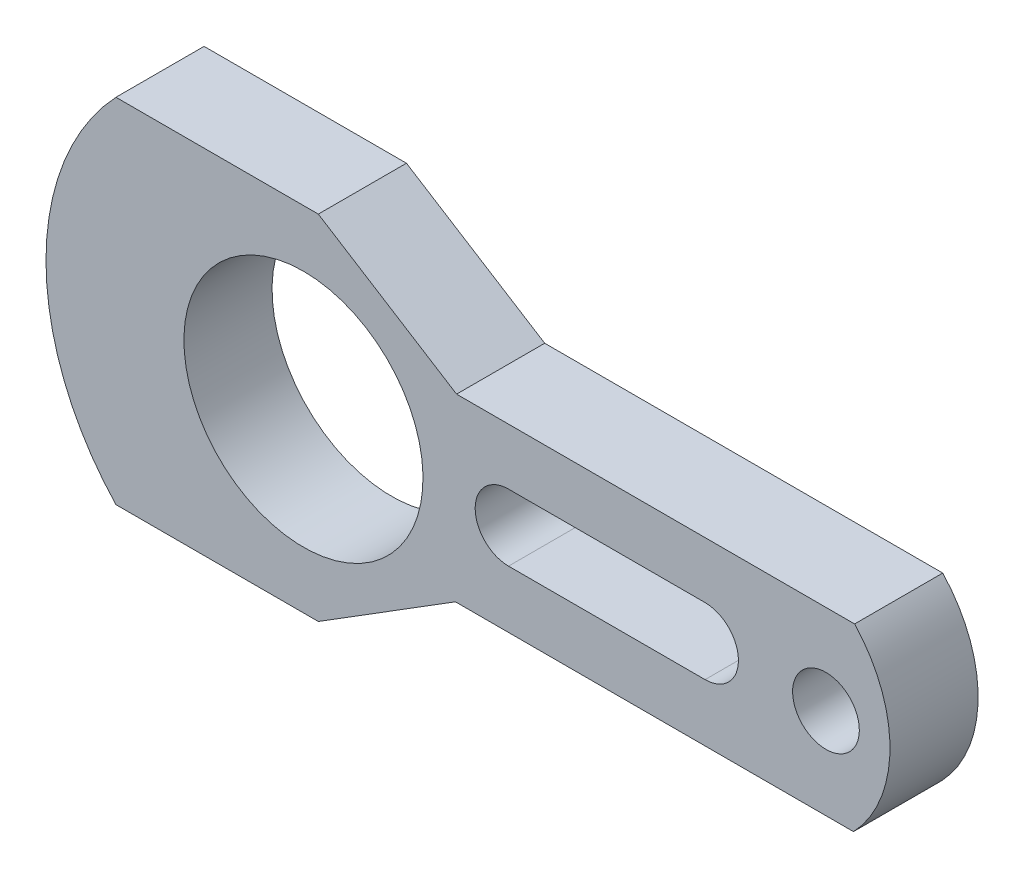
from build123d import *

# Parameters (mm, degrees)
CROQUIS1_R                   = 67.818
CROQUIS1_R_2                 = 18.923
SALIENTE_EXTRUIR1_DEPTH      = 50
CORPS_D_PLACER_COPIER1_ANGLE = 90


with BuildPart() as part:
    # Croquis1 → Saliente-Extruir1 (new body)
    with BuildSketch(Plane.XY):
        with BuildLine():
            Line((50.841156462, -86.860973253), (100.076, -8.434146427))
            Line((100.076, -8.434146427), (100.076, 106.373853573))
            ThreePointArc((100.076, 106.373853573), (0, 146.05), (-100.076, 106.373853573))
            Line((-100.076, 106.373853573), (-100.076, -8.434146427))
            Line((-100.076, -8.434146427), (-51.520843538, -86.217090682))
            Line((-51.520843538, -86.217090682), (-51.520843538, -312.023090682))
            ThreePointArc((-51.520843538, -312.023090682), (-0.468123725, -332.738527707), (50.841156462, -312.666973253))
            Line((50.841156462, -312.666973253), (50.841156462, -86.860973253))
        make_face()
        Circle(CROQUIS1_R, mode=Mode.SUBTRACT)
        with Locations((0, -296.418)):
            Circle(CROQUIS1_R_2, mode=Mode.SUBTRACT)
        with BuildLine():
            Line((18.923, -116.332), (18.923, -227.838))
            ThreePointArc((18.923, -227.838), (0, -246.761), (-18.923, -227.838))
            Line((-18.923, -227.838), (-18.923, -116.332))
            ThreePointArc((-18.923, -116.332), (0, -97.409), (18.923, -116.332))
        make_face(mode=Mode.SUBTRACT)
    extrude(amount=SALIENTE_EXTRUIR1_DEPTH)


with BuildPart() as part_1:
    # Corps-Déplacer/Copier1: moved
    add(part.part.rotate(Axis((0, 0, 0), (0, 0, 1)), CORPS_D_PLACER_COPIER1_ANGLE))


solid = part_1.part
